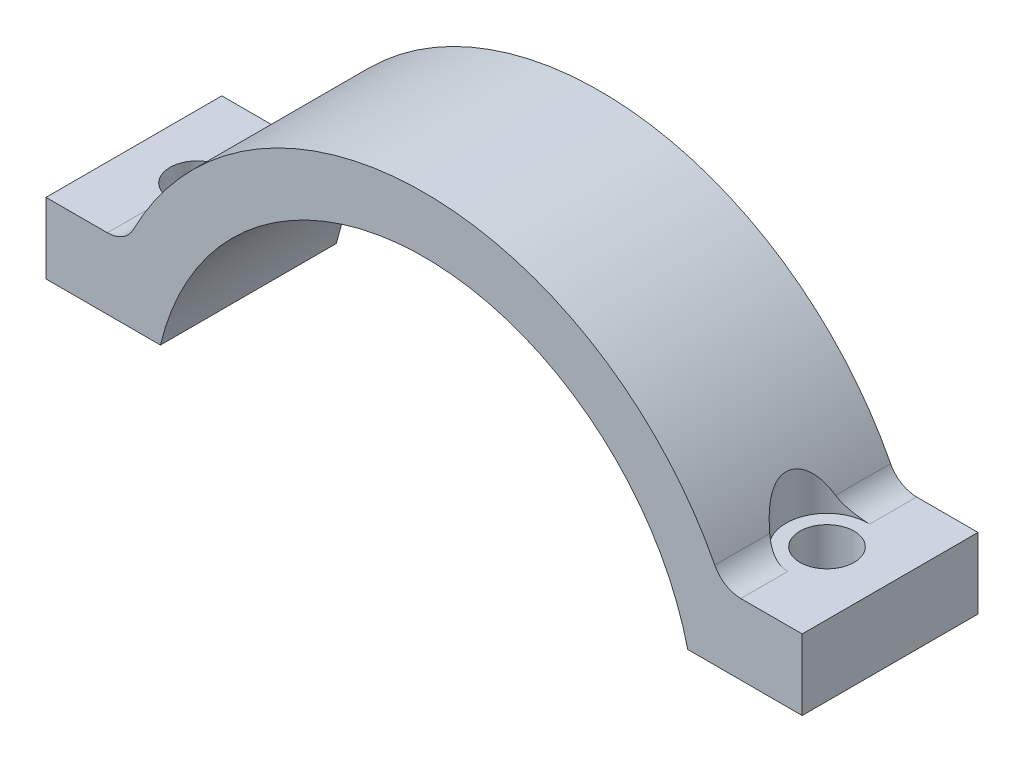
from build123d import *

# Parameters (mm, degrees)
BOSS_EXTRUDE1_DEPTH      = 6
BOSS_EXTRUDE1_DEPTH_BACK = 6
FILLET1_R                = 2
CUT_EXTRUDE2_DEPTH       = 4.826
CUT_EXTRUDE2_DEPTH_BACK  = 4.826
SKETCH3_R                = 1.85
SKETCH4_R                = 2.794
CUT_EXTRUDE3_DEPTH       = 4.826


with BuildPart() as part:
    # Sketch1 → Boss-Extrude1 (new, two sides: drawn at the far end of the back side and taken through both)
    with BuildSketch(Plane.XY.offset(-BOSS_EXTRUDE1_DEPTH_BACK)):
        with BuildLine():
            Line((25.8064, 0), (25.8064, 4.826))
            Line((25.8064, 4.826), (20.361415325, 4.826))
            ThreePointArc((20.361415325, 4.826), (0, 18.0174), (-20.361415325, 4.826))
            Line((-20.361415325, 4.826), (-25.8064, 4.826))
            Line((-25.8064, 4.826), (-25.8064, 0))
            Line((-25.8064, 0), (-17.995098923, 0))
            ThreePointArc((-17.995098923, 0), (0, 14.2074), (17.995098923, 0))
            Line((17.995098923, 0), (25.8064, 0))
        make_face()
    extrude(amount=BOSS_EXTRUDE1_DEPTH + BOSS_EXTRUDE1_DEPTH_BACK)

    # Fillet1
    fillet1_edges = [part.edges().sort_by_distance(p)[0] for p in [
        (20.361415325, 4.826, 0),
        (-20.361415325, 4.826, 0),
    ]]
    fillet(fillet1_edges, radius=FILLET1_R)

    # Sketch3 → Cut-Extrude2 (cut, two sides: drawn at the far end of the back side and taken through both)
    with BuildSketch(Plane(origin=(0, 0, 0), x_dir=(1, 0, 0), z_dir=(0, 1, 0)).offset(-CUT_EXTRUDE2_DEPTH_BACK)):
        with Locations((21.5, 0)):
            Circle(SKETCH3_R)
        with Locations((-21.5, 0)):
            Circle(SKETCH3_R)
    extrude(amount=CUT_EXTRUDE2_DEPTH + CUT_EXTRUDE2_DEPTH_BACK, mode=Mode.SUBTRACT)

    # Sketch4 → Cut-Extrude3 (cut)
    with BuildSketch(Plane(origin=(0, 4.826, 0), x_dir=(1, 0, 0), z_dir=(0, 1, 0))):
        with Locations((-21.5, 0)):
            Circle(SKETCH4_R)
        with Locations((21.5, 0)):
            Circle(SKETCH4_R)
    extrude(amount=CUT_EXTRUDE3_DEPTH, mode=Mode.SUBTRACT)


solid = part.part
